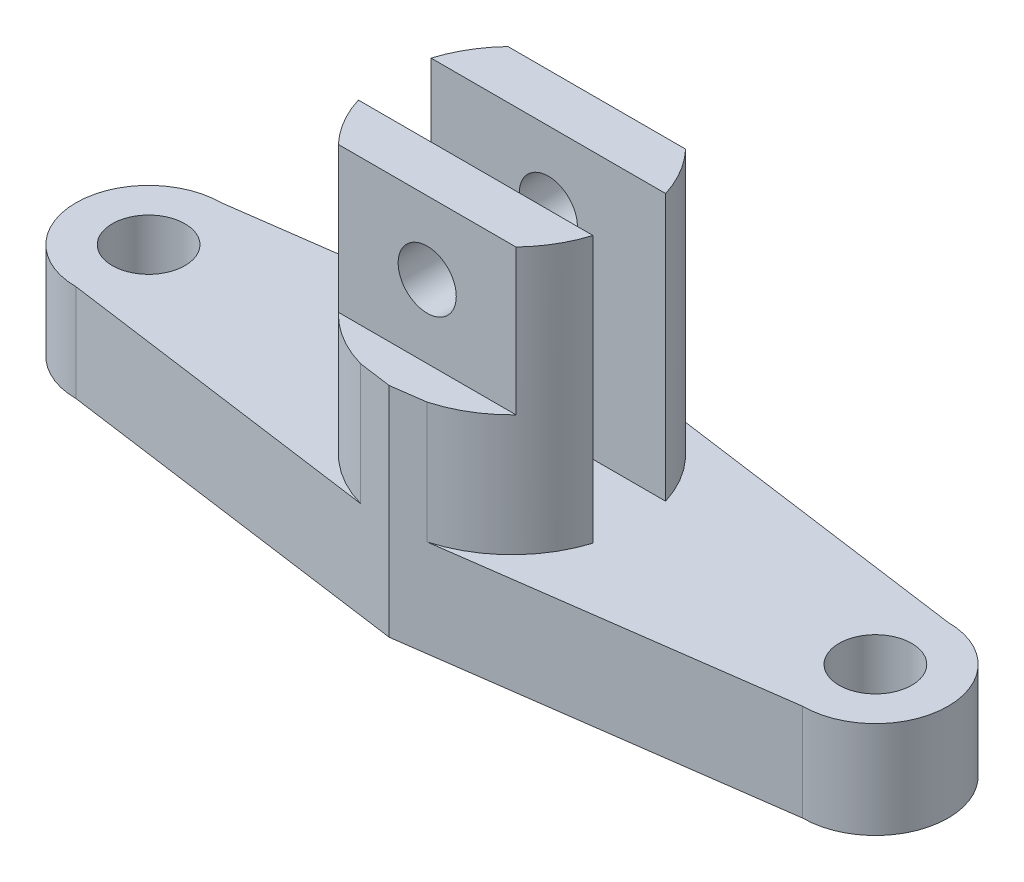
from build123d import *

# Parameters (mm, degrees)
CROQUIS_PLANTA_R           = 7.5
SALIENTE_EXTRUIR1_DEPTH    = 20
SALIENTE_EXTRUIR2_DEPTH    = 45
SALIENTE_EXTRUIR3_DEPTH    = 75
CROQUIS14_R                = 6
CORTAR_EXTRUIR1_DEPTH      = 8.83956507
CORTAR_EXTRUIR1_DEPTH_BACK = 43.83956507


with BuildPart() as part:
    # Croquis Planta → Saliente-Extruir1 (new body)
    with BuildSketch(Plane(origin=(0, 0, 0), x_dir=(1, 0, 0), z_dir=(0, 1, 0))):
        with BuildLine():
            ThreePointArc((-6.856359495, -24.394341401), (-25.33956507, 0), (-6.856359495, 24.394341401))
            Line((-6.856359495, 24.394341401), (-75, 15))
            ThreePointArc((-75, 15), (-90, 0), (-75, -15))
            Line((-75, -15), (-6.856359495, -24.394341401))
        make_face()
        with Locations((-75, 0)):
            Circle(CROQUIS_PLANTA_R, mode=Mode.SUBTRACT)
        with BuildLine():
            ThreePointArc((75, -15), (90, 0), (75, 15))
            Line((75, 15), (6.856359495, 24.394341401))
            ThreePointArc((6.856359495, 24.394341401), (20.196914684, 15.302881924), (25.33956507, 0))
            ThreePointArc((25.33956507, 0), (20.196914684, -15.302881924), (6.856359495, -24.394341401))
            Line((6.856359495, -24.394341401), (75, -15))
        make_face()
        with Locations((75, 0)):
            Circle(CROQUIS_PLANTA_R, mode=Mode.SUBTRACT)
        with BuildLine():
            ThreePointArc((25.33956507, 0), (20.196914684, 15.302881924), (6.856359495, 24.394341401))
            Line((6.856359495, 24.394341401), (0, 25.33956507))
            Line((0, 25.33956507), (-6.856359495, 24.394341401))
            ThreePointArc((-6.856359495, 24.394341401), (-25.33956507, 0), (-6.856359495, -24.394341401))
            Line((-6.856359495, -24.394341401), (0, -25.33956507))
            Line((0, -25.33956507), (6.856359495, -24.394341401))
            ThreePointArc((6.856359495, -24.394341401), (20.196914684, -15.302881924), (25.33956507, 0))
        make_face()
    extrude(amount=SALIENTE_EXTRUIR1_DEPTH)

    # Croquis11 → Saliente-Extruir2 (add)
    with BuildSketch(Plane(origin=(0, 0, 0), x_dir=(1, 0, 0), z_dir=(0, 1, 0))):
        with BuildLine():
            ThreePointArc((24.204205377, 7.5), (21.845030009, 12.840880882), (18.326034976, 17.5))
            Line((18.326034976, 17.5), (-18.326034976, 17.5))
            ThreePointArc((-18.326034976, 17.5), (-21.845030009, 12.840880882), (-24.204205377, 7.5))
            Line((-24.204205377, 7.5), (24.204205377, 7.5))
        make_face()
        with BuildLine():
            ThreePointArc((18.326034976, 17.5), (13.05454839, 21.718018424), (6.856359495, 24.394341401))
            Line((6.856359495, 24.394341401), (0, 25.33956507))
            Line((0, 25.33956507), (-6.856359495, 24.394341401))
            ThreePointArc((-6.856359495, 24.394341401), (-13.05454839, 21.718018424), (-18.326034976, 17.5))
            Line((-18.326034976, 17.5), (18.326034976, 17.5))
        make_face()
        with BuildLine():
            Line((-18.326034976, -17.5), (18.326034976, -17.5))
            ThreePointArc((18.326034976, -17.5), (21.845030009, -12.840880882), (24.204205377, -7.5))
            Line((24.204205377, -7.5), (-24.204205377, -7.5))
            ThreePointArc((-24.204205377, -7.5), (-21.845030009, -12.840880882), (-18.326034976, -17.5))
        make_face()
        with BuildLine():
            Line((0, -25.33956507), (6.856359495, -24.394341401))
            ThreePointArc((6.856359495, -24.394341401), (13.05454839, -21.718018424), (18.326034976, -17.5))
            Line((18.326034976, -17.5), (-18.326034976, -17.5))
            ThreePointArc((-18.326034976, -17.5), (-13.05454839, -21.718018424), (-6.856359495, -24.394341401))
            Line((-6.856359495, -24.394341401), (0, -25.33956507))
        make_face()
    extrude(amount=SALIENTE_EXTRUIR2_DEPTH)

    # Croquis12 → Saliente-Extruir3 (add)
    with BuildSketch(Plane(origin=(0, 0, 0), x_dir=(1, 0, 0), z_dir=(0, 1, 0))):
        with BuildLine():
            ThreePointArc((24.204205377, 7.5), (21.845030009, 12.840880882), (18.326034976, 17.5))
            Line((18.326034976, 17.5), (-18.326034976, 17.5))
            ThreePointArc((-18.326034976, 17.5), (-21.845030009, 12.840880882), (-24.204205377, 7.5))
            Line((-24.204205377, 7.5), (24.204205377, 7.5))
        make_face()
        with BuildLine():
            Line((-18.326034976, -17.5), (18.326034976, -17.5))
            ThreePointArc((18.326034976, -17.5), (21.845030009, -12.840880882), (24.204205377, -7.5))
            Line((24.204205377, -7.5), (-24.204205377, -7.5))
            ThreePointArc((-24.204205377, -7.5), (-21.845030009, -12.840880882), (-18.326034976, -17.5))
        make_face()
    extrude(amount=SALIENTE_EXTRUIR3_DEPTH)

    # Croquis14 → Cortar-Extruir1 (cut, two sides)
    with BuildSketch(Plane(origin=(0, 0, -17.5), x_dir=(-1, 0, 0), z_dir=(0, 0, -1))) as cortar_extruir1_sk:
        with Locations((0, 60)):
            Circle(CROQUIS14_R)
    extrude(amount=CORTAR_EXTRUIR1_DEPTH, mode=Mode.SUBTRACT)
    extrude(cortar_extruir1_sk.sketch, amount=-CORTAR_EXTRUIR1_DEPTH_BACK, mode=Mode.SUBTRACT)


solid = part.part
